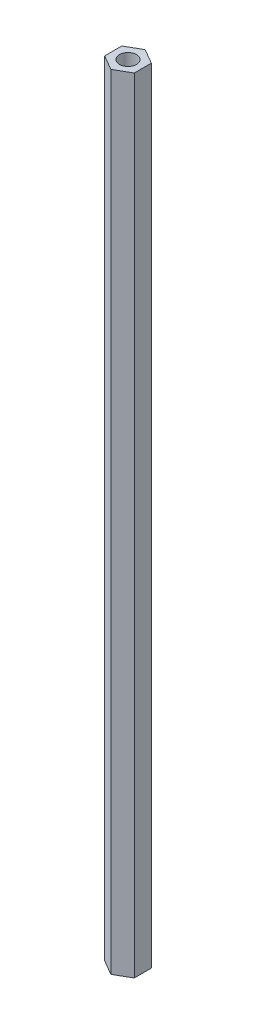
from build123d import *

# Parameters (mm, degrees)
ESQUISSE1_R      = 2.5
EXTRUSION1_DEPTH = 229


with BuildPart() as part:
    # Esquisse1 → Extrusion1 (new body)
    with BuildSketch(Plane(origin=(0, 0, 0), x_dir=(1, 0, 0), z_dir=(0, 1, 0))):
        Polygon((0, 5), (-4.330127019, 2.5), (-4.330127019, -2.5), (0, -5), (4.330127019, -2.5), (4.330127019, 2.5), align=None)
        Circle(ESQUISSE1_R, mode=Mode.SUBTRACT)
    extrude(amount=EXTRUSION1_DEPTH)


solid = part.part
